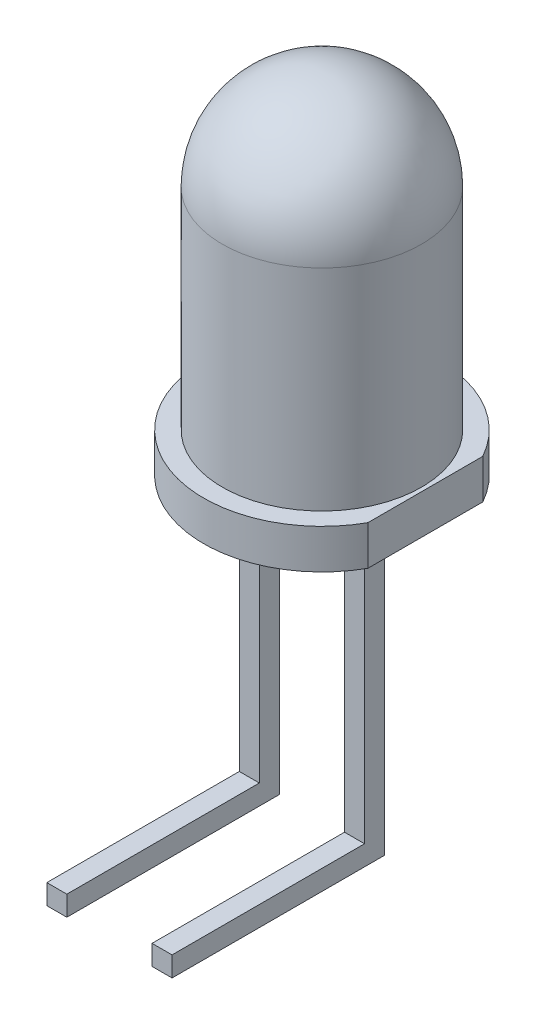
from build123d import *

# Parameters (mm, degrees)
BOSS_EXTRUDE2_DEPTH = 0.9779
SKETCH5_W           = 0.4953
SKETCH5_H           = 7.366
BOSS_EXTRUDE3_DEPTH = 0.4953
SKETCH6_W           = 0.4953
SKETCH6_H           = 0.4953
BOSS_EXTRUDE4_DEPTH = 4.7625
SKETCH7_W           = 0.4953
SKETCH7_H           = 0.4953
BOSS_EXTRUDE5_DEPTH = 4.7625


with BuildPart() as part:
    # Sketch3 → Revolve1 (revolve)
    with BuildSketch(Plane.XY):
        with BuildLine():
            Line((-2.4638, 5.207), (-2.4638, 0))
            Line((-2.4638, 0), (0, 0))
            Line((0, 0), (0, 7.6708))
            ThreePointArc((0, 7.6708), (-1.742169687, 6.949169687), (-2.4638, 5.207))
        make_face()
    revolve(axis=Axis((0, 0, 0), (0, 1, 0)))

    # Sketch4 → Boss-Extrude2 (add)
    with BuildSketch(Plane.XZ):
        with BuildLine():
            Line((2.55905, 1.421492568), (2.55905, -1.421492568))
            ThreePointArc((2.55905, -1.421492568), (-2.92735, 0), (2.55905, 1.421492568))
        make_face()
    extrude(amount=BOSS_EXTRUDE2_DEPTH)

    # Sketch5 → Boss-Extrude3 (add)
    with BuildSketch(Plane.XY):
        with Locations((-1.30175, -4.6609)):
            Rectangle(SKETCH5_W, SKETCH5_H)
        with Locations((1.30175, -4.6609)):
            Rectangle(SKETCH5_W, SKETCH5_H)
    extrude(amount=BOSS_EXTRUDE3_DEPTH)

    # Sketch6 → Boss-Extrude4 (add)
    with BuildSketch(Plane.XY.offset(0.4953)):
        with Locations((-1.30175, -8.09625)):
            Rectangle(SKETCH6_W, SKETCH6_H)
    extrude(amount=BOSS_EXTRUDE4_DEPTH)

    # Sketch7 → Boss-Extrude5 (add)
    with BuildSketch(Plane.XY.offset(0.4953)):
        with Locations((1.30175, -8.09625)):
            Rectangle(SKETCH7_W, SKETCH7_H)
    extrude(amount=BOSS_EXTRUDE5_DEPTH)


solid = part.part
